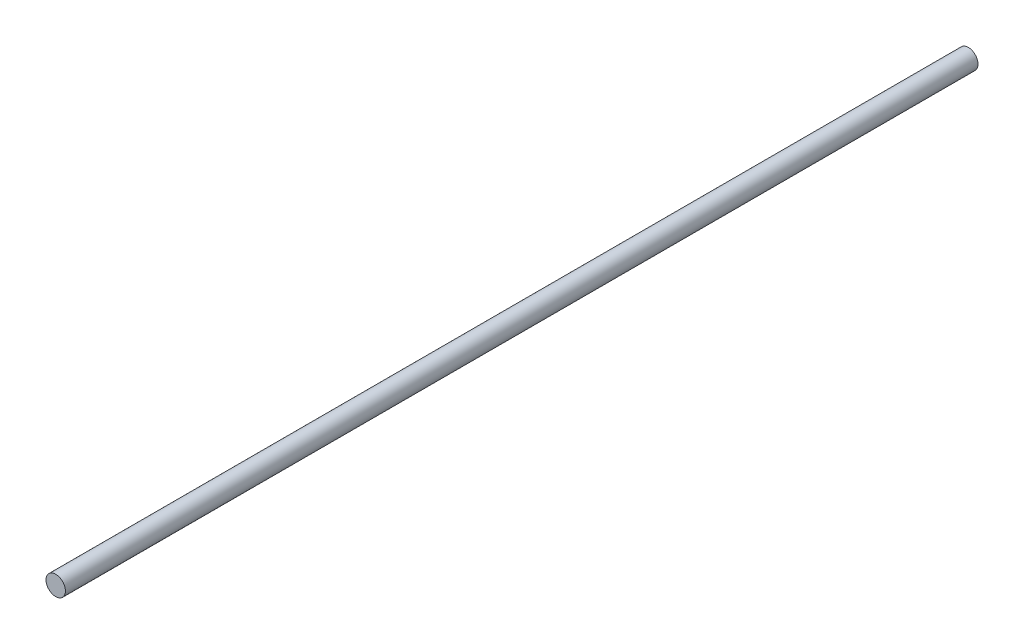
from build123d import *

# Parameters (mm, degrees)
SKETCH2_W = 375.703193978
SKETCH2_H = 4


with BuildPart() as part:
    # Sketch2 → Revolve1 (revolve)
    with BuildSketch(Plane(origin=(0, 0, 0), x_dir=(0, 0, -1), z_dir=(1, 0, 0))):
        with Locations((200, 2)):
            Rectangle(SKETCH2_W, SKETCH2_H)
    revolve(axis=Axis((0, 0, -12.148403011), (0, 0, 1)))


solid = part.part
